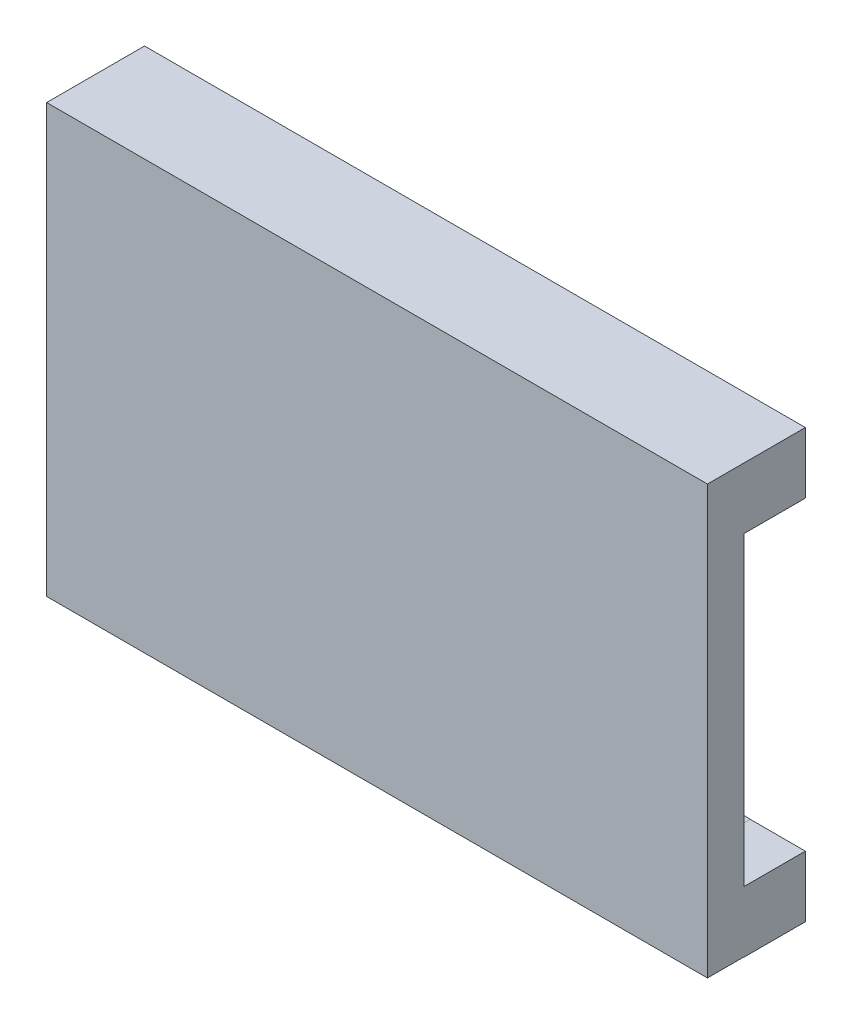
from build123d import *

# Parameters (mm, degrees)
SKETCH1_R             = 1.05
BOSS_EXTRUDE1_DEPTH   = 3
BOSS_EXTRUDE1_2_DEPTH = 3
SKETCH1_3_W           = 54
SKETCH1_3_H           = 24.978925024
BOSS_EXTRUDE2_DEPTH   = 3
BOSS_EXTRUDE4_START   = -3
SKETCH4_W             = 54
SKETCH4_H             = 5
BOSS_EXTRUDE4_DEPTH   = 3
BOSS_EXTRUDE5_DEPTH   = 5
BOSS_EXTRUDE6_DEPTH   = 5
SKETCH6_W             = 45
SKETCH6_H             = 1
CUT_EXTRUDE1_DEPTH    = 2.5
SKETCH7_W             = 45
SKETCH7_H             = 1
CUT_EXTRUDE2_DEPTH    = 2.5


with BuildPart() as part:
    # Sketch1 → Boss-Extrude1 (new body)
    with BuildSketch(Plane.XY):
        with Locations((-22.5, 0)):
            Circle(SKETCH1_R)
    extrude(amount=-BOSS_EXTRUDE1_DEPTH)



with BuildPart() as body_2:
    # Sketch1 → Boss-Extrude1 2 (new body)
    with BuildSketch(Plane.XY):
        with Locations((22.5, 0)):
            Circle(SKETCH1_R)
    extrude(amount=-BOSS_EXTRUDE1_2_DEPTH)


with BuildPart() as part_1:
    add(part.part)

    add(body_2.part)  # Boss-Extrude2 merges body 2
    # Sketch1_3 → Boss-Extrude2 (add)
    with BuildSketch(Plane.XY):
        with Locations((0, -0.010537488)):
            Rectangle(SKETCH1_3_W, SKETCH1_3_H)
    extrude(amount=BOSS_EXTRUDE2_DEPTH)

    # Sketch4 → Boss-Extrude4 (add)
    with BuildSketch(Plane.XY.offset(3).offset(BOSS_EXTRUDE4_START)):
        with Locations((0, 14.978925024)):
            Rectangle(SKETCH4_W, SKETCH4_H)
        with Locations((0, -14.978925024)):
            Rectangle(SKETCH4_W, SKETCH4_H)
    extrude(amount=BOSS_EXTRUDE4_DEPTH)

    # Sketch3 → Boss-Extrude5 (add)
    with BuildSketch(Plane(origin=(0, 0, 0), x_dir=(-1, 0, 0), z_dir=(0, 0, -1))):
        with BuildLine():
            Line((-27, 12.478925024), (-22.5, 12.478925024))
            Line((-22.5, 12.478925024), (-1, 11.35215777))
            Line((-1, 11.35215777), (-1, 13.104559375))
            Line((-1, 13.104559375), (-22.5, 14.23132663))
            ThreePointArc((-22.5, 14.23132663), (-23.25, 14.98132663), (-22.5, 15.73132663))
            Line((-22.5, 15.73132663), (22.5, 15.73132663))
            ThreePointArc((22.5, 15.73132663), (23.25, 14.98132663), (22.5, 14.23132663))
            Line((22.5, 14.23132663), (1, 13.104559375))
            Line((1, 13.104559375), (1, 11.35215777))
            Line((1, 11.35215777), (22.5, 12.478925024))
            Line((22.5, 12.478925024), (27, 12.478925024))
            Line((27, 12.478925024), (27, 17.478925024))
            Line((27, 17.478925024), (-27, 17.478925024))
            Line((-27, 17.478925024), (-27, 12.478925024))
        make_face()
    extrude(amount=BOSS_EXTRUDE5_DEPTH)

    # Sketch3_4 → Boss-Extrude6 (add)
    with BuildSketch(Plane(origin=(0, 0, 0), x_dir=(-1, 0, 0), z_dir=(0, 0, -1))):
        with BuildLine():
            Line((1, -13.125634351), (1, -11.373232745))
            Line((1, -11.373232745), (22.5, -12.5))
            Line((22.5, -12.5), (27, -12.5))
            Line((27, -12.5), (27, -17.5))
            Line((27, -17.5), (-27, -17.5))
            Line((-27, -17.5), (-27, -12.5))
            Line((-27, -12.5), (-22.5, -12.5))
            Line((-22.5, -12.5), (-1, -11.373232745))
            Line((-1, -11.373232745), (-1, -13.125634351))
            Line((-1, -13.125634351), (-22.5, -14.252401605))
            ThreePointArc((-22.5, -14.252401605), (-23.25, -15.002401605), (-22.5, -15.752401605))
            Line((-22.5, -15.752401605), (22.5, -15.752401605))
            ThreePointArc((22.5, -15.752401605), (23.25, -15.002401605), (22.5, -14.252401605))
            Line((22.5, -14.252401605), (1, -13.125634351))
        make_face()
    extrude(amount=BOSS_EXTRUDE6_DEPTH)

    # Sketch6 → Cut-Extrude1 (cut, symmetric)
    with BuildSketch(Plane.XZ.offset(-12.478925024)):
        with Locations((0, -0.5)):
            Rectangle(SKETCH6_W, SKETCH6_H)
    extrude(amount=CUT_EXTRUDE1_DEPTH, both=True, mode=Mode.SUBTRACT)

    # Sketch7 → Cut-Extrude2 (cut, symmetric)
    with BuildSketch(Plane(origin=(0, -12.5, 0), x_dir=(1, 0, 0), z_dir=(0, 1, 0))):
        with Locations((0, 0.5)):
            Rectangle(SKETCH7_W, SKETCH7_H)
    extrude(amount=CUT_EXTRUDE2_DEPTH, both=True, mode=Mode.SUBTRACT)


solid = part_1.part
